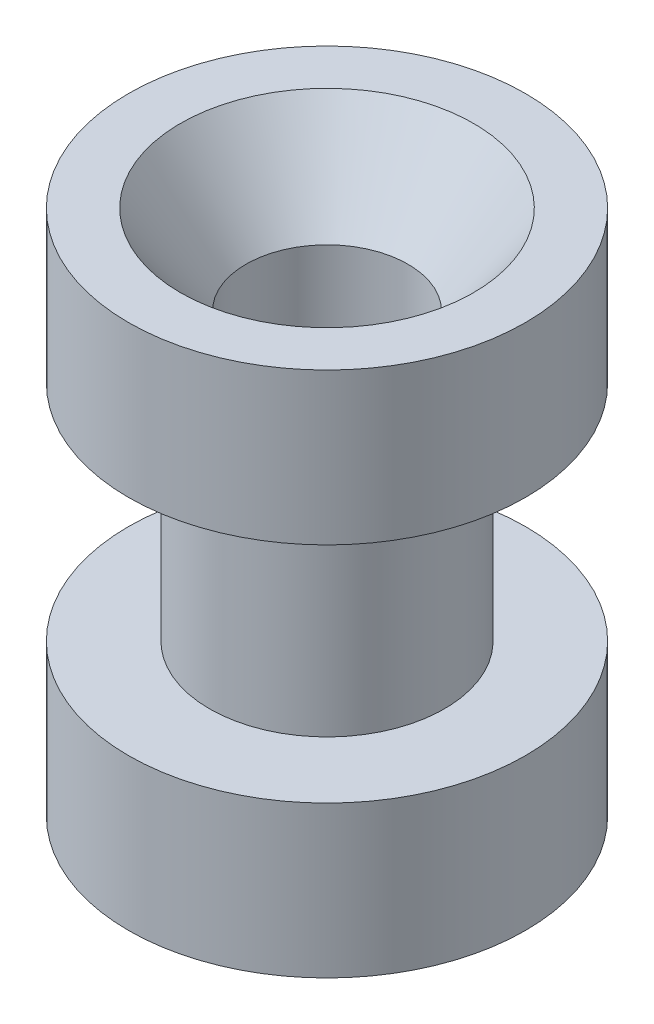
from build123d import *

# Parameters (mm, degrees)
SKETCH1_R           = 6.223
BOSS_EXTRUDE1_DEPTH = 4.7498
SKETCH2_R           = 3.683
BOSS_EXTRUDE2_DEPTH = 7.0104
SKETCH3_R           = 6.223
BOSS_EXTRUDE3_DEPTH = 4.7498
SKETCH4_R           = 2.54
CUT_EXTRUDE1_DEPTH  = 16.51


with BuildPart() as part:
    # Sketch1 → Boss-Extrude1 (new body)
    with BuildSketch(Plane(origin=(0, 0, 0), x_dir=(1, 0, 0), z_dir=(0, 1, 0))):
        Circle(SKETCH1_R)
    extrude(amount=BOSS_EXTRUDE1_DEPTH)

    # Sketch2 → Boss-Extrude2 (add)
    with BuildSketch(Plane(origin=(0, 4.7498, 0), x_dir=(1, 0, 0), z_dir=(0, 1, 0))):
        Circle(SKETCH2_R)
    extrude(amount=BOSS_EXTRUDE2_DEPTH)

    # Sketch3 → Boss-Extrude3 (add)
    with BuildSketch(Plane(origin=(0, 11.7602, 0), x_dir=(1, 0, 0), z_dir=(0, 1, 0))):
        Circle(SKETCH3_R)
    extrude(amount=BOSS_EXTRUDE3_DEPTH)

    # Sketch4 → Cut-Extrude1 (cut)
    with BuildSketch(Plane(origin=(0, 16.51, 0), x_dir=(1, 0, 0), z_dir=(0, 1, 0))):
        Circle(SKETCH4_R)
    extrude(amount=-CUT_EXTRUDE1_DEPTH, mode=Mode.SUBTRACT)

    # Sketch5 → Cut-Revolve1 (revolve, cut)
    with BuildSketch(Plane(origin=(0, 0, 0), x_dir=(0, 0, -1), z_dir=(1, 0, 0))):
        Polygon((0, 16.51), (0, 13.716), (2.54, 13.716), (4.5974, 16.51), align=None)
    revolve(axis=Axis((0, 16.51, 0), (0, -1, 0)), mode=Mode.SUBTRACT)


solid = part.part
